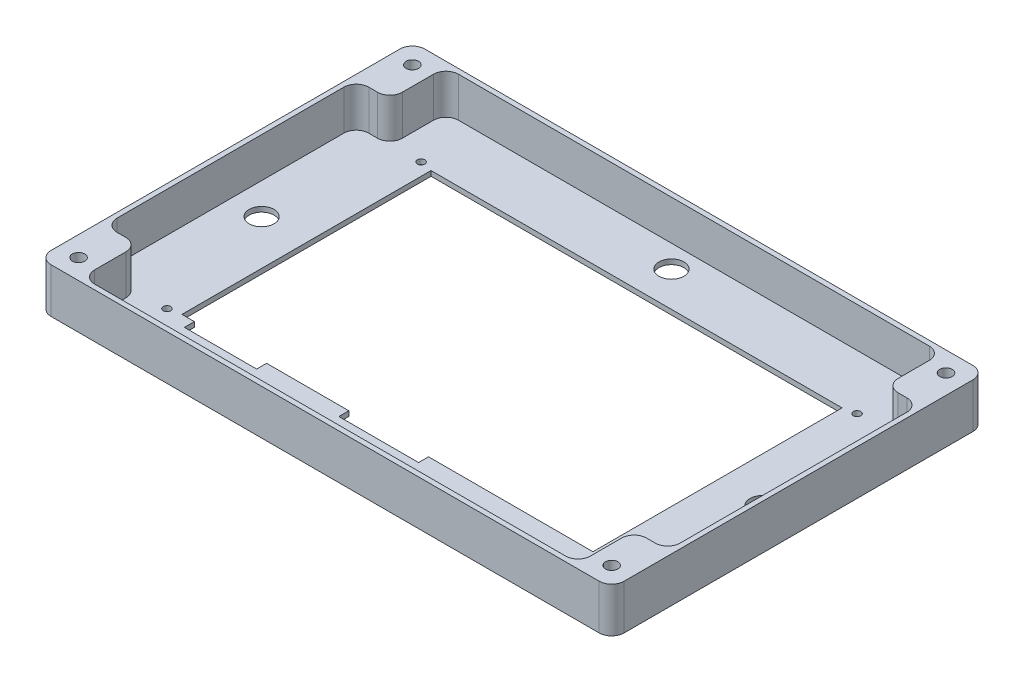
from build123d import *

# Parameters (mm, degrees)
SKETCH_1_W                       = 230
SKETCH_1_H                       = 150
EXTRUDE_1_DEPTH                  = 18
CUT_EXTRUDE_2_DEPTH              = 16
FILLET_1_R                       = 5
SKETCH_3_R                       = 2.5
CUT_EXTRUDE_4_DEPTH              = 19
SKETCH_5_W                       = 165
SKETCH_5_H                       = 100
CUT_EXTRUDE_5_DEPTH              = 19
CUT_EXTRUDE_8_REACH              = 20
SKETCH_7_R                       = 1.5
CUT_EXTRUDE_9_REACH              = 20
SKETCH_8_R                       = 5
CUT_EXTRUDE_10_REACH             = 20
SKETCH_6_W                       = 29
SKETCH_6_H                       = 4
CUT_EXTRUDE_11_REACH             = 20
SKETCH_6_3_W                     = 32
SKETCH_6_3_H                     = 4
CUT_EXTRUDE_11_DIRECTION_2_DEPTH = 1


with BuildPart() as part:
    # 草图1 → 凸台-拉伸1 (new body)
    with BuildSketch(Plane(origin=(0, 0, 0), x_dir=(1, 0, 0), z_dir=(0, 1, 0))):
        with Locations((115, 75)):
            Rectangle(SKETCH_1_W, SKETCH_1_H)
    extrude(amount=EXTRUDE_1_DEPTH)

    # 草图2 → 切除-拉伸2 (cut)
    with BuildSketch(Plane(origin=(0, 18, 0), x_dir=(1, 0, 0), z_dir=(0, 1, 0))):
        Polygon((2, 125.5), (2, 24.5), (15.5, 24.5), (15.5, 2), (214.5, 2), (214.5, 24.5), (228, 24.5), (228, 125.5), (214.5, 125.5), (214.5, 148), (15.5, 148), (15.5, 125.5), align=None)
    extrude(amount=-CUT_EXTRUDE_2_DEPTH, mode=Mode.SUBTRACT)

    # 圆角1
    fillet_1_edges = [part.edges().sort_by_distance(p)[0] for p in [
        (2, 10, -125.5),
        (15.5, 10, -125.5),
        (15.5, 10, -148),
        (214.5, 10, -148),
        (214.5, 10, -125.5),
        (228, 10, -125.5),
        (228, 10, -24.5),
        (214.5, 10, -24.5),
        (214.5, 10, -2),
        (15.5, 10, -2),
        (15.5, 10, -24.5),
        (2, 10, -24.5),
        (0, 9, -150),
        (230, 9, -150),
        (230, 9, 0),
        (0, 9, 0),
    ]]
    fillet(fillet_1_edges, radius=FILLET_1_R)

    # 草图3 → 切除-拉伸4 (cut, through all)
    with BuildSketch(Plane(origin=(0, 18, 0), x_dir=(1, 0, 0), z_dir=(0, 1, 0))):
        with Locations((8, 142)):
            Circle(SKETCH_3_R)
        with Locations((222.21463853, 142)):
            Circle(SKETCH_3_R)
        with Locations((8, 8.013915663)):
            Circle(SKETCH_3_R)
        with Locations((222, 8)):
            Circle(SKETCH_3_R)
    extrude(amount=-CUT_EXTRUDE_4_DEPTH, mode=Mode.SUBTRACT)

    # 草图5 → 切除-拉伸5 (cut, through all)
    with BuildSketch(Plane.XZ):
        with Locations((115, -75)):
            Rectangle(SKETCH_5_W, SKETCH_5_H)
    extrude(amount=-CUT_EXTRUDE_5_DEPTH, mode=Mode.SUBTRACT)

    # 草图7 → 切除-拉伸8 (cut, up to next)
    with BuildSketch(Plane.XZ, mode=Mode.PRIVATE) as cut_extrude_8_sk1:
        with Locations((27.5, -24)):
            Circle(SKETCH_7_R)
    cut_extrude_8_tool1 = extrude(cut_extrude_8_sk1.sketch, amount=-CUT_EXTRUDE_8_REACH, mode=Mode.PRIVATE) & part.part
    add(cut_extrude_8_tool1.solids().sort_by_distance((27.5, 0, -24))[0], mode=Mode.SUBTRACT)
    # 草图7 → 切除-拉伸8 (cut, up to next)
    with BuildSketch(Plane.XZ, mode=Mode.PRIVATE) as cut_extrude_8_sk2:
        with Locations((202.5, -126)):
            Circle(SKETCH_7_R)
    cut_extrude_8_tool2 = extrude(cut_extrude_8_sk2.sketch, amount=-CUT_EXTRUDE_8_REACH, mode=Mode.PRIVATE) & part.part
    add(cut_extrude_8_tool2.solids().sort_by_distance((202.5, 0, -126))[0], mode=Mode.SUBTRACT)
    # 草图7 → 切除-拉伸8 (cut, up to next)
    with BuildSketch(Plane.XZ, mode=Mode.PRIVATE) as cut_extrude_8_sk3:
        with Locations((27.5, -126)):
            Circle(SKETCH_7_R)
    cut_extrude_8_tool3 = extrude(cut_extrude_8_sk3.sketch, amount=-CUT_EXTRUDE_8_REACH, mode=Mode.PRIVATE) & part.part
    add(cut_extrude_8_tool3.solids().sort_by_distance((27.5, 0, -126))[0], mode=Mode.SUBTRACT)
    # 草图7 → 切除-拉伸8 (cut, up to next)
    with BuildSketch(Plane.XZ, mode=Mode.PRIVATE) as cut_extrude_8_sk4:
        with Locations((202.5, -24)):
            Circle(SKETCH_7_R)
    cut_extrude_8_tool4 = extrude(cut_extrude_8_sk4.sketch, amount=-CUT_EXTRUDE_8_REACH, mode=Mode.PRIVATE) & part.part
    add(cut_extrude_8_tool4.solids().sort_by_distance((202.5, 0, -24))[0], mode=Mode.SUBTRACT)

    # 草图8 → 切除-拉伸9 (cut, up to next)
    with BuildSketch(Plane.XZ, mode=Mode.PRIVATE) as cut_extrude_9_sk1:
        with Locations((14.5, -75)):
            Circle(SKETCH_8_R)
    cut_extrude_9_tool1 = extrude(cut_extrude_9_sk1.sketch, amount=-CUT_EXTRUDE_9_REACH, mode=Mode.PRIVATE) & part.part
    add(cut_extrude_9_tool1.solids().sort_by_distance((14.5, 0, -75))[0], mode=Mode.SUBTRACT)
    # 草图8 → 切除-拉伸9 (cut, up to next)
    with BuildSketch(Plane.XZ, mode=Mode.PRIVATE) as cut_extrude_9_sk2:
        with Locations((115, -11)):
            Circle(SKETCH_8_R)
    cut_extrude_9_tool2 = extrude(cut_extrude_9_sk2.sketch, amount=-CUT_EXTRUDE_9_REACH, mode=Mode.PRIVATE) & part.part
    add(cut_extrude_9_tool2.solids().sort_by_distance((115, 0, -11))[0], mode=Mode.SUBTRACT)
    # 草图8 → 切除-拉伸9 (cut, up to next)
    with BuildSketch(Plane.XZ, mode=Mode.PRIVATE) as cut_extrude_9_sk3:
        with Locations((215.5, -75)):
            Circle(SKETCH_8_R)
    cut_extrude_9_tool3 = extrude(cut_extrude_9_sk3.sketch, amount=-CUT_EXTRUDE_9_REACH, mode=Mode.PRIVATE) & part.part
    add(cut_extrude_9_tool3.solids().sort_by_distance((215.5, 0, -75))[0], mode=Mode.SUBTRACT)
    # 草图8 → 切除-拉伸9 (cut, up to next)
    with BuildSketch(Plane.XZ, mode=Mode.PRIVATE) as cut_extrude_9_sk4:
        with Locations((115, -139)):
            Circle(SKETCH_8_R)
    cut_extrude_9_tool4 = extrude(cut_extrude_9_sk4.sketch, amount=-CUT_EXTRUDE_9_REACH, mode=Mode.PRIVATE) & part.part
    add(cut_extrude_9_tool4.solids().sort_by_distance((115, 0, -139))[0], mode=Mode.SUBTRACT)

    # 草图6 → 切除-拉伸10 (cut, up to next)
    with BuildSketch(Plane.XZ, mode=Mode.PRIVATE) as cut_extrude_10_sk1:
        with Locations((52, -23)):
            Rectangle(SKETCH_6_W, SKETCH_6_H)
    cut_extrude_10_tool1 = extrude(cut_extrude_10_sk1.sketch, amount=-CUT_EXTRUDE_10_REACH, mode=Mode.PRIVATE) & part.part
    add(cut_extrude_10_tool1.solids().sort_by_distance((52, 0, -23))[0], mode=Mode.SUBTRACT)

    # 草图6<3> → 切除-拉伸11 (cut, up to next)
    with BuildSketch(Plane.XZ, mode=Mode.PRIVATE) as cut_extrude_11_sk1:
        with Locations((115.5, -23)):
            Rectangle(SKETCH_6_3_W, SKETCH_6_3_H)
    cut_extrude_11_tool1 = extrude(cut_extrude_11_sk1.sketch, amount=-CUT_EXTRUDE_11_REACH, mode=Mode.PRIVATE) & part.part
    add(cut_extrude_11_tool1.solids().sort_by_distance((115.5, 0, -23))[0], mode=Mode.SUBTRACT)

    # 草图6<3> → 切除-拉伸11 direction 2 (cut)
    with BuildSketch(Plane.XZ):
        with Locations((115.5, -23)):
            Rectangle(SKETCH_6_3_W, SKETCH_6_3_H)
    extrude(amount=CUT_EXTRUDE_11_DIRECTION_2_DEPTH, mode=Mode.SUBTRACT)


solid = part.part
